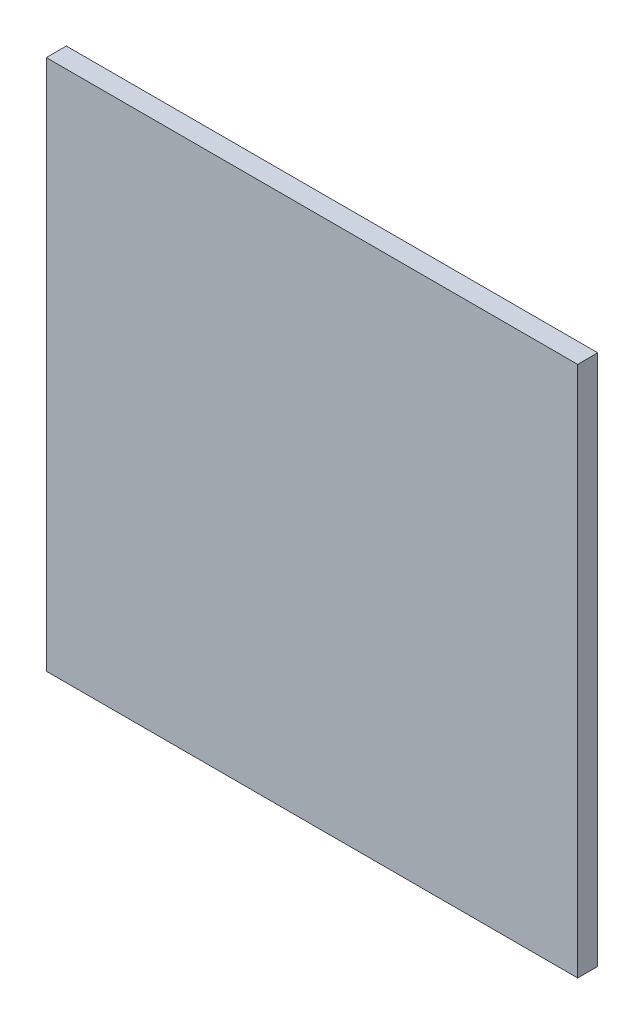
from build123d import *

# Parameters (mm, degrees)
SKETCH1_W           = 530
SKETCH1_H           = 530
BOSS_EXTRUDE1_DEPTH = 20


with BuildPart() as part:
    # Sketch1 → Boss-Extrude1 (new body)
    with BuildSketch(Plane.XY):
        Rectangle(SKETCH1_W, SKETCH1_H)
    extrude(amount=BOSS_EXTRUDE1_DEPTH)


solid = part.part
